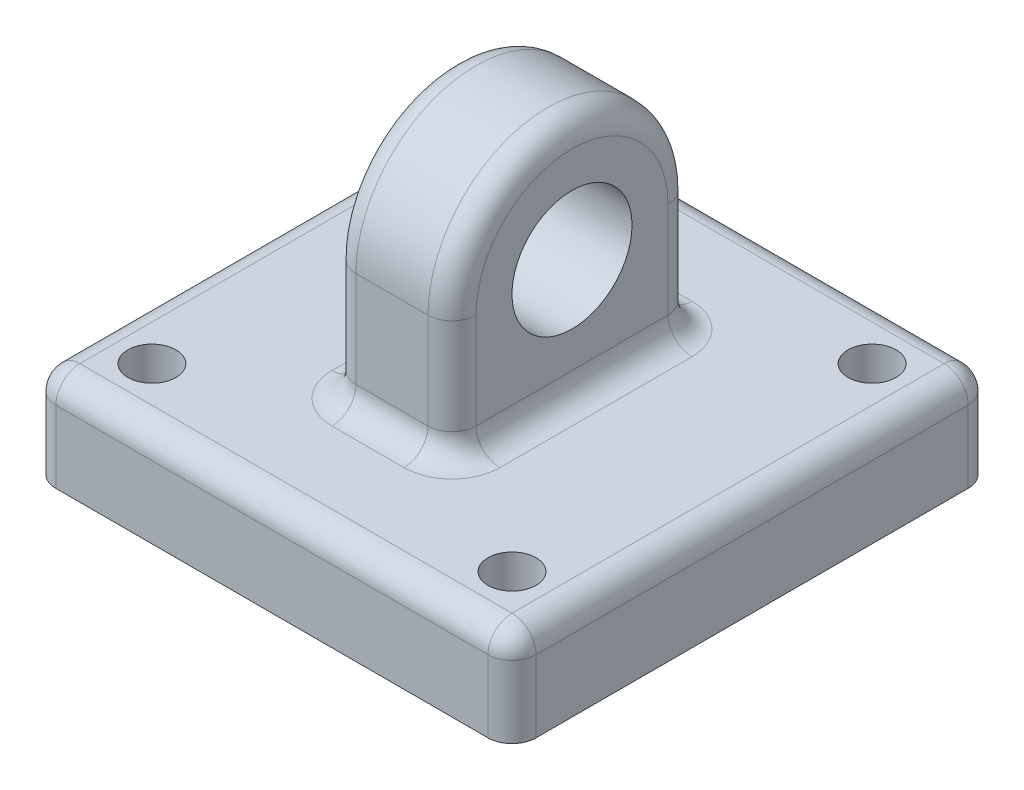
from build123d import *

# Parameters (mm, degrees)
ESQUISSE2_R             = 2.5
BOSS_EXTRU_1_DEPTH      = 2.5
ESQUISSE4_W             = 20
ESQUISSE4_H             = 20
BOSS_EXTRU_2_DEPTH      = 4
ENL_V_MAT_EXTRU_1_REACH = 6
ESQUISSE5_R             = 1
CONG_1_R                = 1


with BuildPart() as part:
    # Esquisse2 → Boss.-Extru.1 (new body, symmetric)
    with BuildSketch(Plane(origin=(0, 0, 0), x_dir=(0, 0, -1), z_dir=(1, 0, 0))):
        with BuildLine():
            Line((5, 0), (5, -5))
            Line((5, -5), (-5, -5))
            Line((-5, -5), (-5, 0))
            ThreePointArc((-5, 0), (0, 5), (5, 0))
        make_face()
        Circle(ESQUISSE2_R, mode=Mode.SUBTRACT)
    extrude(amount=BOSS_EXTRU_1_DEPTH, both=True)

    # Esquisse4 → Boss.-Extru.2 (add)
    with BuildSketch(Plane.XZ.offset(5)):
        Rectangle(ESQUISSE4_W, ESQUISSE4_H)
    extrude(amount=BOSS_EXTRU_2_DEPTH)

    # Esquisse5 → Enlèv. mat.-Extru.1 (cut, up to next)
    with BuildSketch(Plane(origin=(0, -5, 0), x_dir=(1, 0, 0), z_dir=(0, 1, 0)), mode=Mode.PRIVATE) as enl_v_mat_extru_1_sk1:
        with Locations(Location((7.5, -7.5, 0), (0, 0, 270))):  # turned: the seam where the file's is
            Circle(ESQUISSE5_R)
    enl_v_mat_extru_1_tool1 = extrude(enl_v_mat_extru_1_sk1.sketch, amount=-ENL_V_MAT_EXTRU_1_REACH, mode=Mode.PRIVATE) & part.part
    add(enl_v_mat_extru_1_tool1.solids().sort_by_distance((7.5, -5, 7.5))[0], mode=Mode.SUBTRACT)
    # Esquisse5 → Enlèv. mat.-Extru.1 (cut, up to next)
    with BuildSketch(Plane(origin=(0, -5, 0), x_dir=(1, 0, 0), z_dir=(0, 1, 0)), mode=Mode.PRIVATE) as enl_v_mat_extru_1_sk2:
        with Locations(Location((7.5, 7.5, 0), (0, 0, 270))):  # turned: the seam where the file's is
            Circle(ESQUISSE5_R)
    enl_v_mat_extru_1_tool2 = extrude(enl_v_mat_extru_1_sk2.sketch, amount=-ENL_V_MAT_EXTRU_1_REACH, mode=Mode.PRIVATE) & part.part
    add(enl_v_mat_extru_1_tool2.solids().sort_by_distance((7.5, -5, -7.5))[0], mode=Mode.SUBTRACT)
    # Esquisse5 → Enlèv. mat.-Extru.1 (cut, up to next)
    with BuildSketch(Plane(origin=(0, -5, 0), x_dir=(1, 0, 0), z_dir=(0, 1, 0)), mode=Mode.PRIVATE) as enl_v_mat_extru_1_sk3:
        with Locations(Location((-7.5, 7.5, 0), (0, 0, 270))):  # turned: the seam where the file's is
            Circle(ESQUISSE5_R)
    enl_v_mat_extru_1_tool3 = extrude(enl_v_mat_extru_1_sk3.sketch, amount=-ENL_V_MAT_EXTRU_1_REACH, mode=Mode.PRIVATE) & part.part
    add(enl_v_mat_extru_1_tool3.solids().sort_by_distance((-7.5, -5, -7.5))[0], mode=Mode.SUBTRACT)
    # Esquisse5 → Enlèv. mat.-Extru.1 (cut, up to next)
    with BuildSketch(Plane(origin=(0, -5, 0), x_dir=(1, 0, 0), z_dir=(0, 1, 0)), mode=Mode.PRIVATE) as enl_v_mat_extru_1_sk4:
        with Locations(Location((-7.5, -7.5, 0), (0, 0, 270))):  # turned: the seam where the file's is
            Circle(ESQUISSE5_R)
    enl_v_mat_extru_1_tool4 = extrude(enl_v_mat_extru_1_sk4.sketch, amount=-ENL_V_MAT_EXTRU_1_REACH, mode=Mode.PRIVATE) & part.part
    add(enl_v_mat_extru_1_tool4.solids().sort_by_distance((-7.5, -5, 7.5))[0], mode=Mode.SUBTRACT)

    # Congé1
    cong_1_edges = [part.edges().sort_by_distance(p)[0] for p in [
        (2.5, -5, 0),
        (2.5, -2.5, -5),
        (-10, -5, 0),
        (-10, -7, 10),
        (0, -5, -10),
        (-10, -7, -10),
        (10, -5, 0),
        (10, -7, -10),
        (0, -5, 10),
        (10, -7, 10),
        (2.5, 5, 0),
        (-2.5, -2.5, -5),
        (-2.5, -5, 0),
        (-2.5, -2.5, 5),
        (-2.5, 5, 0),
        (0, -5, -5),
        (0, -5, 5),
        (2.5, -2.5, 5),
    ]]
    fillet(cong_1_edges, radius=CONG_1_R)


solid = part.part
